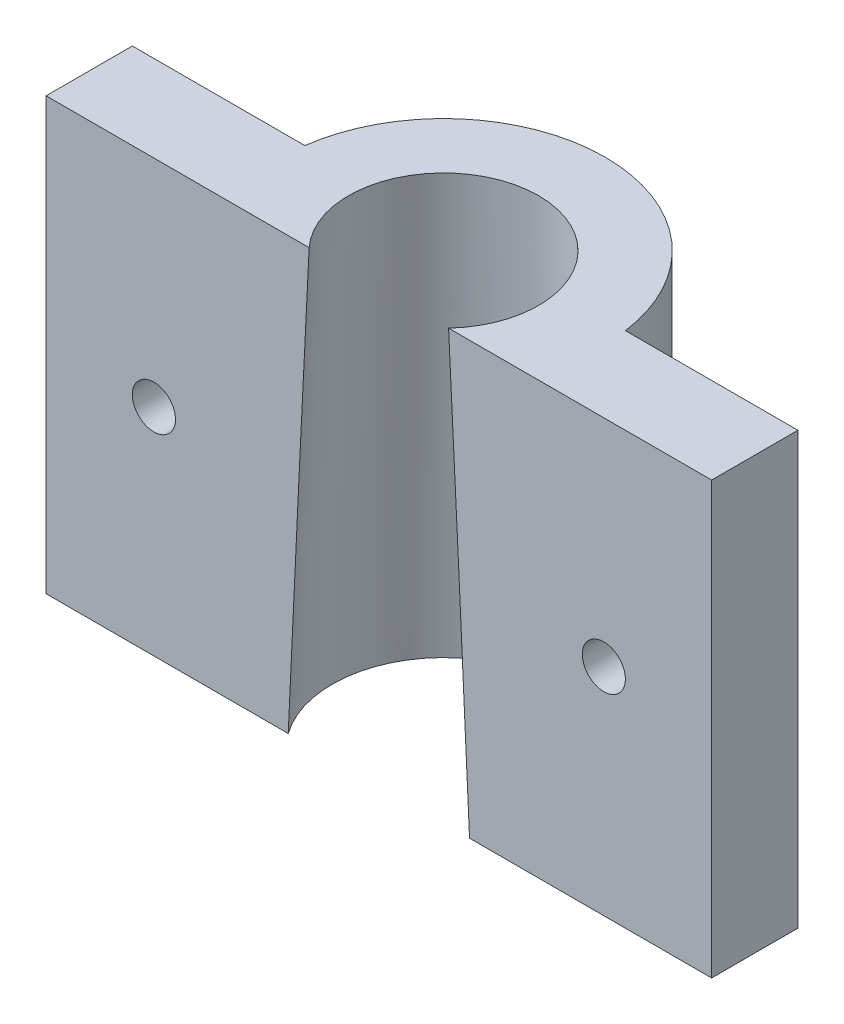
from build123d import *

# Parameters (mm, degrees)
RESSALTO_EXTRUS_O3_DEPTH = 60
ESBO_O5_R                = 6
CORTE_EXTRUS_O1_DEPTH    = 17
ESBO_O7_W                = 30.866068748
ESBO_O7_H                = 32.5
ESBO_O7_H_2              = 7.5
CORTE_EXTRUS_O2_DEPTH    = 15
ESBO_O8_R                = 1
CORTE_EXTRUS_O3_DEPTH    = 5


with BuildPart() as part:
    # Esboço4 → Ressalto-extrusão3 (new body)
    with BuildSketch(Plane(origin=(0, 0, 0), x_dir=(1, 0, 0), z_dir=(0, 1, 0))):
        with BuildLine():
            Line((15.433034374, -3), (-15.433034374, -3))
            Line((-15.433034374, -3), (-15.433034374, 1))
            Line((-15.433034374, 1), (-7.433034374, 1))
            ThreePointArc((-7.433034374, 1), (0, 7.5), (7.433034374, 1))
            Line((7.433034374, 1), (15.433034374, 1))
            Line((15.433034374, 1), (15.433034374, -3))
        make_face()
    extrude(amount=RESSALTO_EXTRUS_O3_DEPTH)

    # Esboço5 → Corte-extrusão1 (cut)
    with BuildSketch(Plane(origin=(0, 0, 0), x_dir=(1, 0, 0), z_dir=(0, 1, 0))):
        Circle(ESBO_O5_R)
    extrude(amount=CORTE_EXTRUS_O1_DEPTH, mode=Mode.SUBTRACT)

    # Esboço6 → Corte-Revolução1 (revolve, cut)
    with BuildSketch(Plane.XY):
        Polygon((0, 17), (-5.75, 17), (-3.75, 70), (0, 70), align=None)
    revolve(axis=Axis((0, 70, 0), (0, -1, 0)), mode=Mode.SUBTRACT)

    # Esboço7 → Corte-extrusão2 (cut)
    with BuildSketch(Plane.XY.offset(3)):
        with Locations((0, 16.25)):
            Rectangle(ESBO_O7_W, ESBO_O7_H)
        with Locations((0, 56.25)):
            Rectangle(ESBO_O7_W, ESBO_O7_H_2)
    extrude(amount=-CORTE_EXTRUS_O2_DEPTH, mode=Mode.SUBTRACT)

    # Esboço8 → Corte-extrusão3 (cut, through all)
    with BuildSketch(Plane(origin=(0, 0, -1), x_dir=(-1, 0, 0), z_dir=(0, 0, -1))):
        with Locations((-10.433034374, 42.5)):
            Circle(ESBO_O8_R)
        with Locations((10.433034374, 42.5)):
            Circle(ESBO_O8_R)
    extrude(amount=-CORTE_EXTRUS_O3_DEPTH, mode=Mode.SUBTRACT)


solid = part.part
